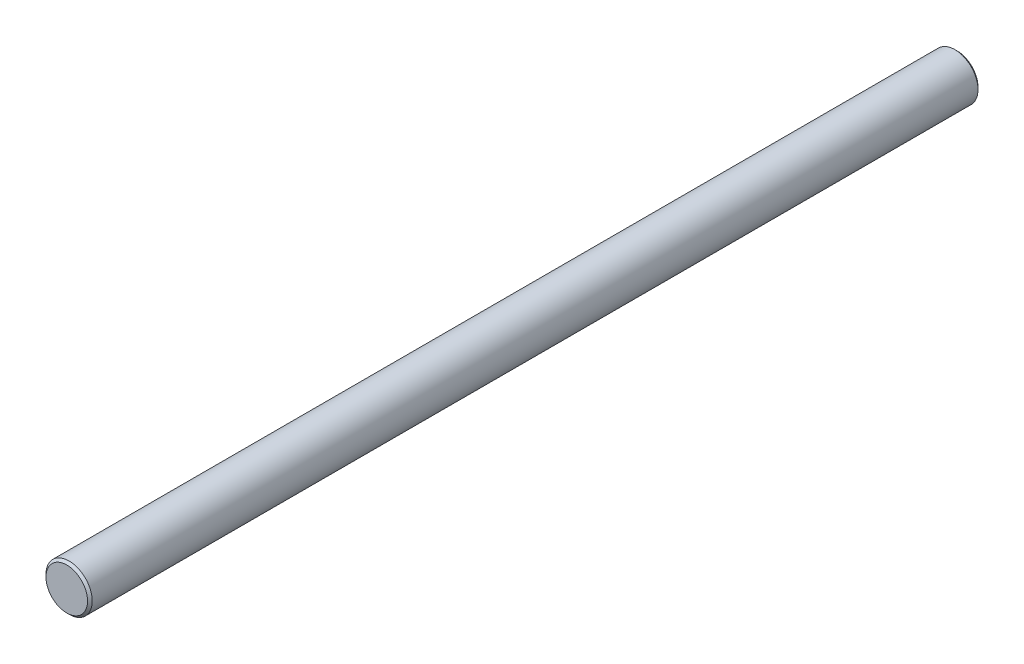
from build123d import *

# Parameters (mm, degrees)
SKETCH1_R           = 10
BOSS_EXTRUDE1_DEPTH = 385
CHAMFER1_SIZE       = 1


with BuildPart() as part:
    # Sketch1 → Boss-Extrude1 (new body)
    with BuildSketch(Plane.XY):
        Circle(SKETCH1_R)
    extrude(amount=BOSS_EXTRUDE1_DEPTH)

    # Chamfer1
    chamfer1_edges = [part.edges().sort_by_distance(p)[0] for p in [
        (-10, 0, 0),
        (-10, 0, 385),
    ]]
    chamfer(chamfer1_edges, length=CHAMFER1_SIZE)


solid = part.part
